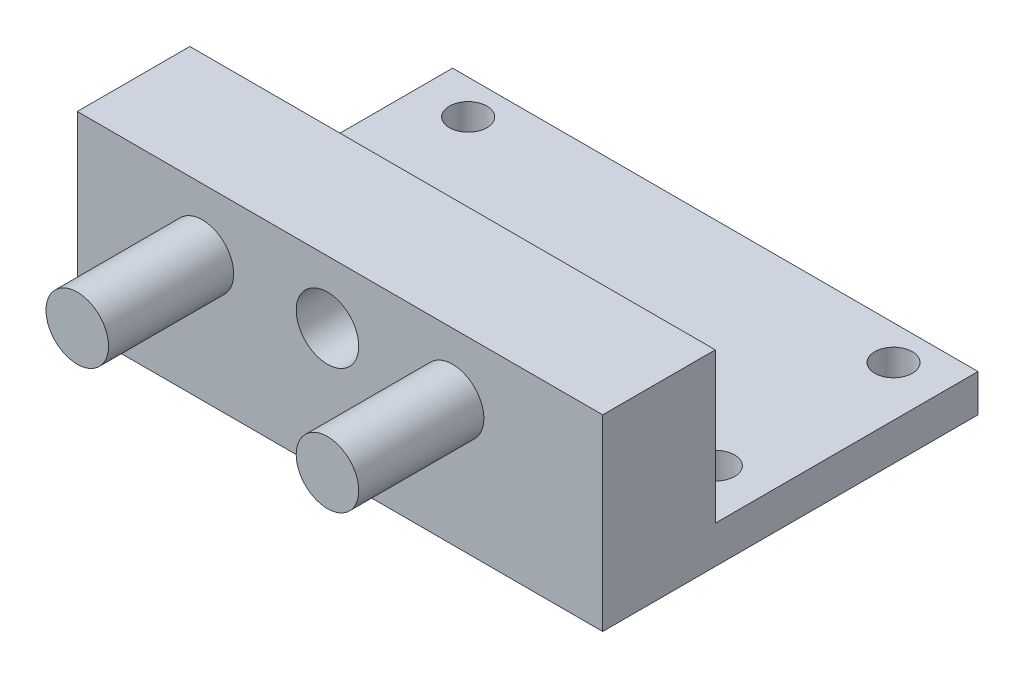
from build123d import *

# Parameters (mm, degrees)
SKETCH1_W           = 42
SKETCH1_H           = 21
SKETCH1_R           = 1.5
BOSS_EXTRUDE1_DEPTH = 3
SKETCH1_3_W         = 42
SKETCH1_3_H         = 9
BOSS_EXTRUDE2_DEPTH = 15
SKETCH2_R           = 2.5
BOSS_EXTRUDE3_DEPTH = 10
SKETCH2_4_R         = 2.5
CUT_EXTRUDE2_DEPTH  = 10


with BuildPart() as part:
    # Sketch1 → Boss-Extrude1 (new body)
    with BuildSketch(Plane(origin=(0, 0, 0), x_dir=(1, 0, 0), z_dir=(0, 1, 0))):
        with Locations((0, 4.5)):
            Rectangle(SKETCH1_W, SKETCH1_H)
        with Locations((-17.044088176, -2)):
            Circle(SKETCH1_R, mode=Mode.SUBTRACT)
        with Locations((17.044088176, -2)):
            Circle(SKETCH1_R, mode=Mode.SUBTRACT)
        with Locations((-17, 12.248496994)):
            Circle(SKETCH1_R, mode=Mode.SUBTRACT)
        with Locations((17, 12.248496994)):
            Circle(SKETCH1_R, mode=Mode.SUBTRACT)
    extrude(amount=BOSS_EXTRUDE1_DEPTH)

    # Sketch1_3 → Boss-Extrude2 (add)
    with BuildSketch(Plane(origin=(0, 0, 0), x_dir=(1, 0, 0), z_dir=(0, 1, 0))):
        with Locations((0, -10.5)):
            Rectangle(SKETCH1_3_W, SKETCH1_3_H)
    extrude(amount=BOSS_EXTRUDE2_DEPTH)

    # Sketch2 → Boss-Extrude3 (add)
    with BuildSketch(Plane.XY.offset(15)):
        with Locations((-11, 10)):
            Circle(SKETCH2_R)
        with Locations((9, 10)):
            Circle(SKETCH2_R)
    extrude(amount=BOSS_EXTRUDE3_DEPTH)

    # Sketch2_4 → Cut-Extrude2 (cut)
    with BuildSketch(Plane.XY.offset(15)):
        with Locations((-1, 10)):
            Circle(SKETCH2_4_R)
    extrude(amount=-CUT_EXTRUDE2_DEPTH, mode=Mode.SUBTRACT)


solid = part.part
